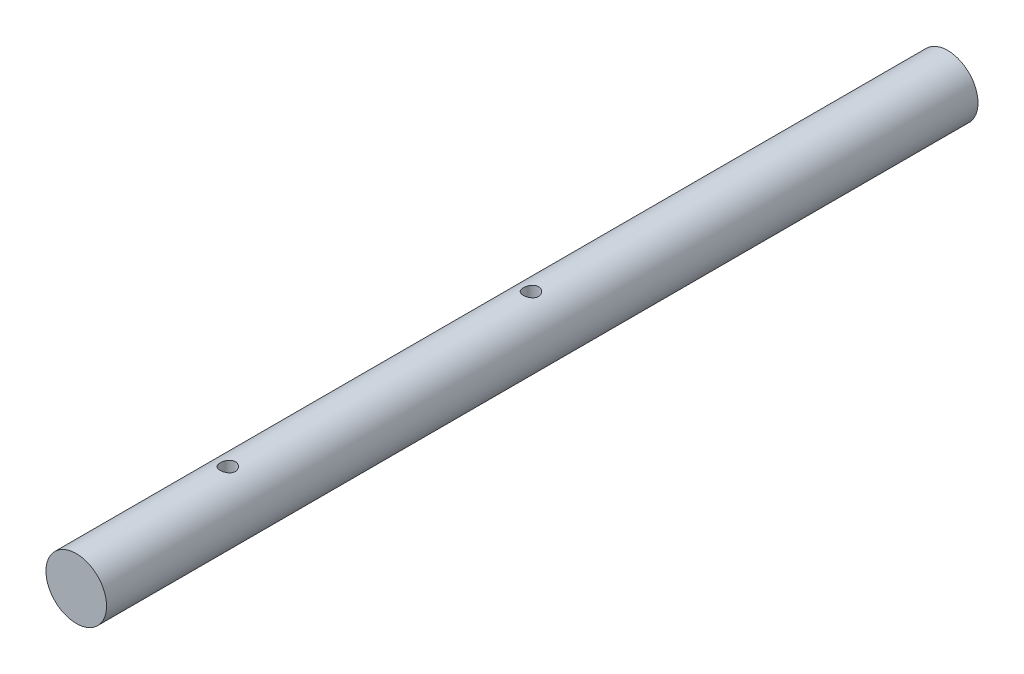
from build123d import *

# Parameters (mm, degrees)
SKETCH_1_R          = 8
EXTRUDE_1_DEPTH     = 230
SKETCH_2_R          = 2
CUT_EXTRUDE_1_DEPTH = 148


with BuildPart() as part:
    # 草图1 → 凸台-拉伸1 (new body)
    with BuildSketch(Plane.XY):
        with Locations((-17.814060708, 40.735649312)):
            Circle(SKETCH_1_R)
    extrude(amount=EXTRUDE_1_DEPTH)

    # 草图2 → 切除-拉伸1 (cut)
    with BuildSketch(Plane(origin=(0, 0, 0), x_dir=(1, 0, 0), z_dir=(0, 1, 0))):
        with Locations((-17.814060708, -110)):
            Circle(SKETCH_2_R)
        with Locations((-17.814060708, -190)):
            Circle(SKETCH_2_R)
    extrude(amount=CUT_EXTRUDE_1_DEPTH, mode=Mode.SUBTRACT)


solid = part.part
